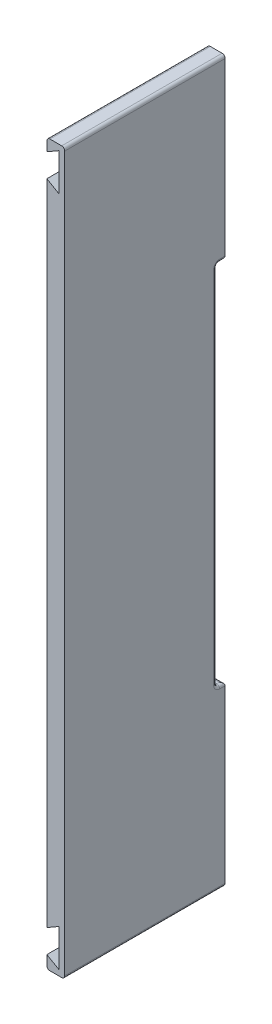
from build123d import *

# Parameters (mm, degrees)
BOSS_EXTRUDE1_DEPTH = 53
CUT_EXTRUDE1_DEPTH  = 52
FILLET1_R           = 1
FILLET2_R           = 1


with BuildPart() as part:
    # Sketch2 → Boss-Extrude1 (new body)
    with BuildSketch(Plane.XY):
        Polygon((0, 0), (0, -4.14), (4.00969762, -1.825), (4.00969762, -14.175), (0, -11.86), (0, -19), (0, -219), (0, -226.14), (4.00969762, -223.825), (4.00969762, -236.175), (0, -233.86), (0, -238), (5.9, -238), (5.9, -229.334408546), (5.9, -8.665591454), (5.9, 0), align=None)
    extrude(amount=BOSS_EXTRUDE1_DEPTH)

    # Sketch3 → Cut-Extrude1 (cut)
    with BuildSketch(Plane(origin=(0, 0, 0), x_dir=(0, 0, -1), z_dir=(1, 0, 0))):
        Polygon((0, -119), (0, -58.5), (-2.8, -58.5), (-2.8, -179.5), (0, -179.5), align=None)
    extrude(amount=CUT_EXTRUDE1_DEPTH, mode=Mode.SUBTRACT)

    # Fillet1
    fillet1_edges = [part.edges().sort_by_distance(p)[0] for p in [
        (2.95, -179.5, 0),
        (2.95, -58.5, 0),
        (5.9, -119, 2.8),
        (2.95, -58.5, 2.8),
        (0, -119, 2.8),
        (0, -58.5, 1.4),
        (2.95, -179.5, 2.8),
        (0, -179.5, 1.4),
        (5.9, -58.5, 1.4),
        (5.9, -179.5, 1.4),
    ]]
    fillet(fillet1_edges, radius=FILLET1_R)

    # Fillet2
    fillet2_edges = [part.edges().sort_by_distance(p)[0] for p in [
        (5.9, 0, 26.5),
        (5.9, -238, 26.5),
        (0, -238, 26.5),
        (0, 0, 26.5),
    ]]
    fillet(fillet2_edges, radius=FILLET2_R)


solid = part.part
